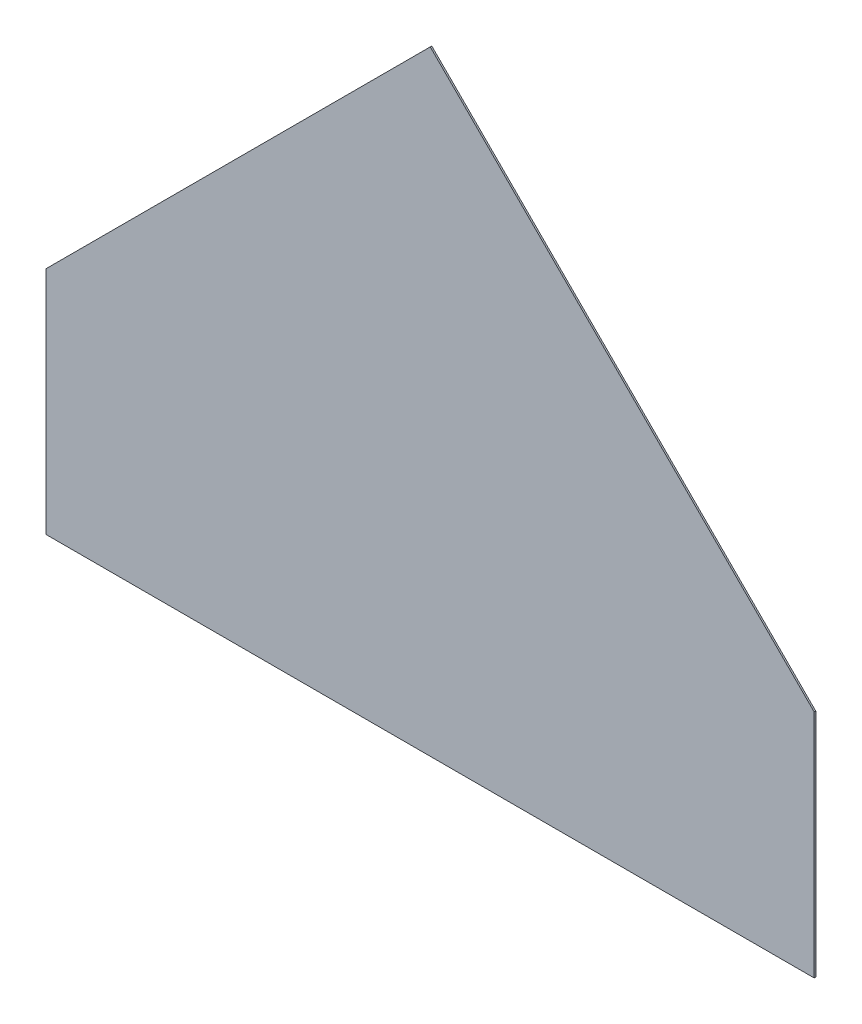
from build123d import *

# Parameters (mm, degrees)
BOSS_EXTRUDE1_DEPTH = 0.1


with BuildPart() as part:
    # Sketch1 → Boss-Extrude1 (new body)
    with BuildSketch(Plane.XY):
        Polygon((0, 0), (-25, 0), (-25, 15), (-3.786796564, 36.213203436), (0, 40), (25, 15), (25, 0), align=None)
    extrude(amount=BOSS_EXTRUDE1_DEPTH)


solid = part.part
